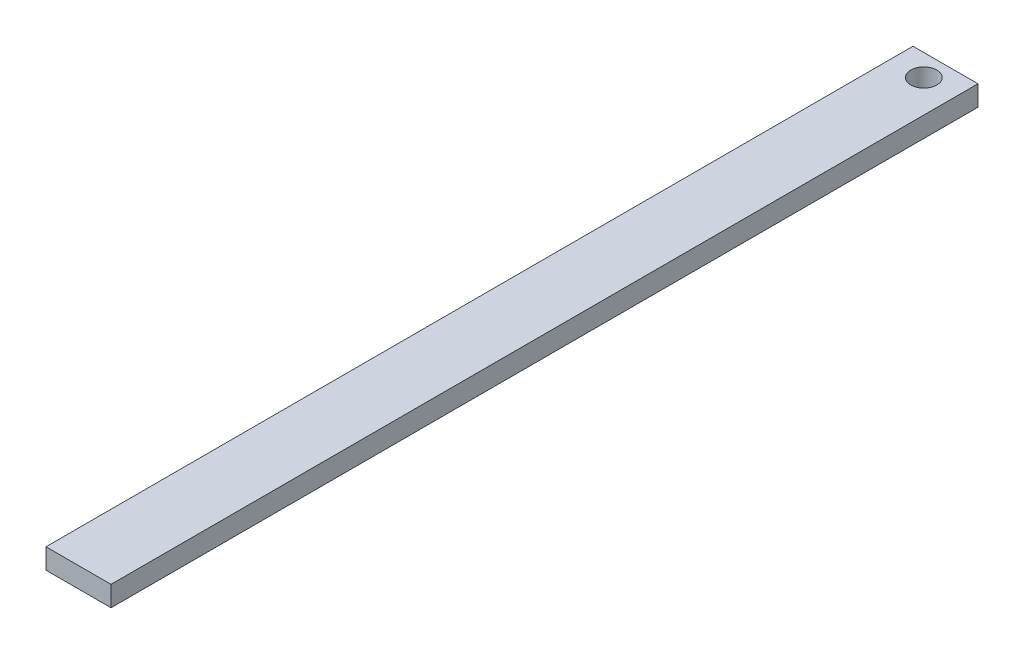
from build123d import *

# Parameters (mm, degrees)
SKETCH1_W           = 7.62
SKETCH1_H           = 2.38125
BOSS_EXTRUDE1_DEPTH = 101.6
SKETCH2_R           = 1.524
CUT_EXTRUDE1_DEPTH  = 3.38125


with BuildPart() as part:
    # Sketch1 → Boss-Extrude1 (new body)
    with BuildSketch(Plane.XY):
        with Locations((3.81, 1.190625)):
            Rectangle(SKETCH1_W, SKETCH1_H)
    extrude(amount=BOSS_EXTRUDE1_DEPTH)

    # Sketch2 → Cut-Extrude1 (cut, through all)
    with BuildSketch(Plane(origin=(0, 2.38125, 0), x_dir=(1, 0, 0), z_dir=(0, 1, 0))):
        with Locations((3.81, -2.54)):
            Circle(SKETCH2_R)
    extrude(amount=-CUT_EXTRUDE1_DEPTH, mode=Mode.SUBTRACT)


solid = part.part
